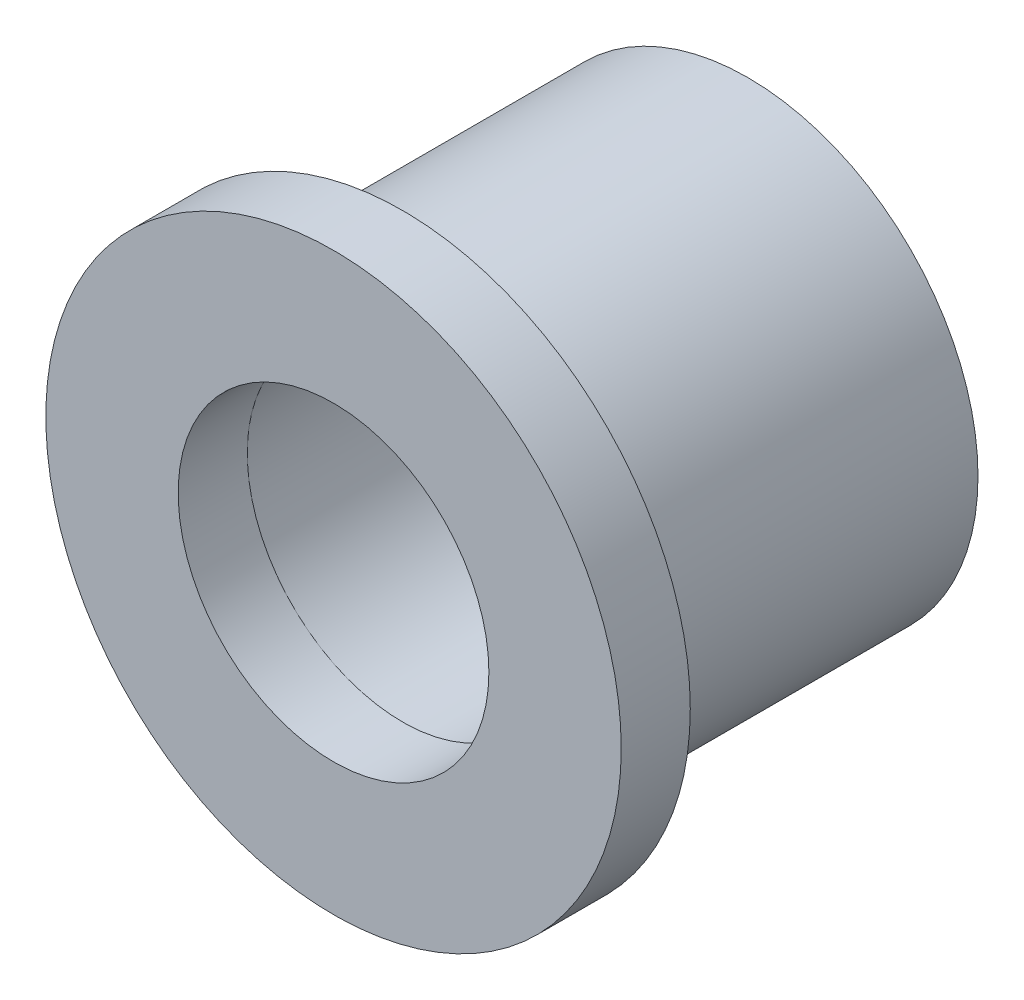
from build123d import *

# Parameters (mm, degrees)
SKETCH1_R           = 15.875
SKETCH1_R_2         = 8.5725
BOSS_EXTRUDE1_DEPTH = 3.81
SKETCH2_R           = 12.7
SKETCH2_R_2         = 8.636
BOSS_EXTRUDE2_DEPTH = 19.05


with BuildPart() as part:
    # Sketch1 → Boss-Extrude1 (new body)
    with BuildSketch(Plane.XY):
        Circle(SKETCH1_R)
        Circle(SKETCH1_R_2, mode=Mode.SUBTRACT)
    extrude(amount=BOSS_EXTRUDE1_DEPTH)

    # Sketch2 → Boss-Extrude2 (add)
    with BuildSketch(Plane(origin=(0, 0, 0), x_dir=(-1, 0, 0), z_dir=(0, 0, -1))):
        Circle(SKETCH2_R)
        Circle(SKETCH2_R_2, mode=Mode.SUBTRACT)
    extrude(amount=BOSS_EXTRUDE2_DEPTH)


solid = part.part
